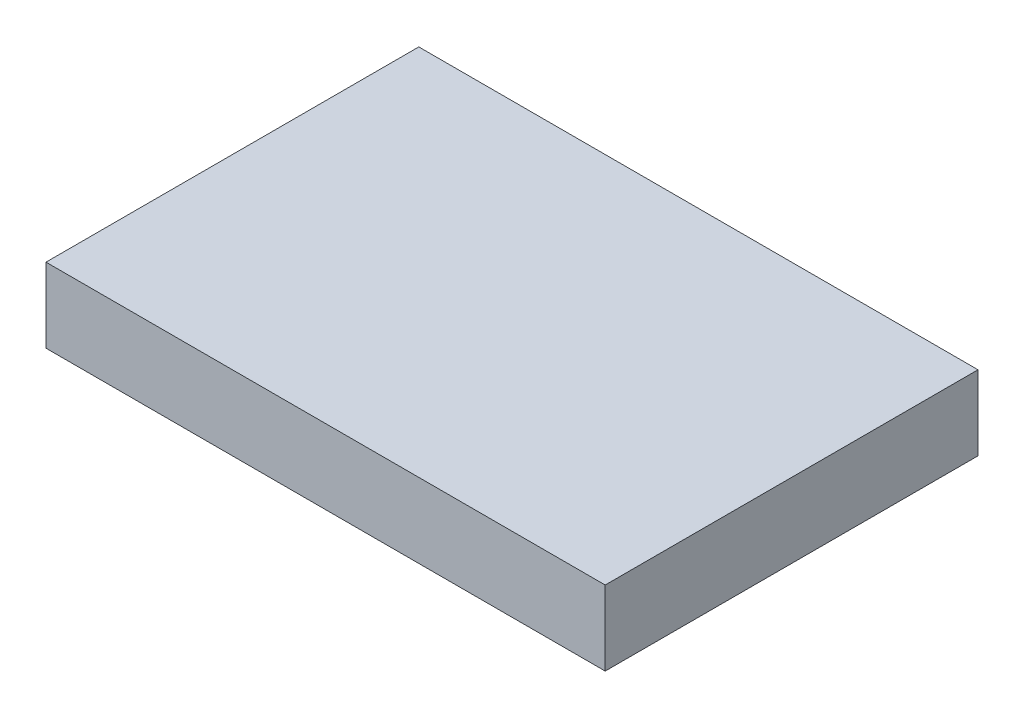
from build123d import *

# Parameters (mm, degrees)
SKETCH1_W           = 91440
SKETCH1_H           = 60960
BOSS_EXTRUDE1_DEPTH = 12192


with BuildPart() as part:
    # Sketch1 → Boss-Extrude1 (new body)
    with BuildSketch(Plane(origin=(0, 0, 0), x_dir=(1, 0, 0), z_dir=(0, 1, 0))):
        Rectangle(SKETCH1_W, SKETCH1_H)
    extrude(amount=BOSS_EXTRUDE1_DEPTH)


solid = part.part
